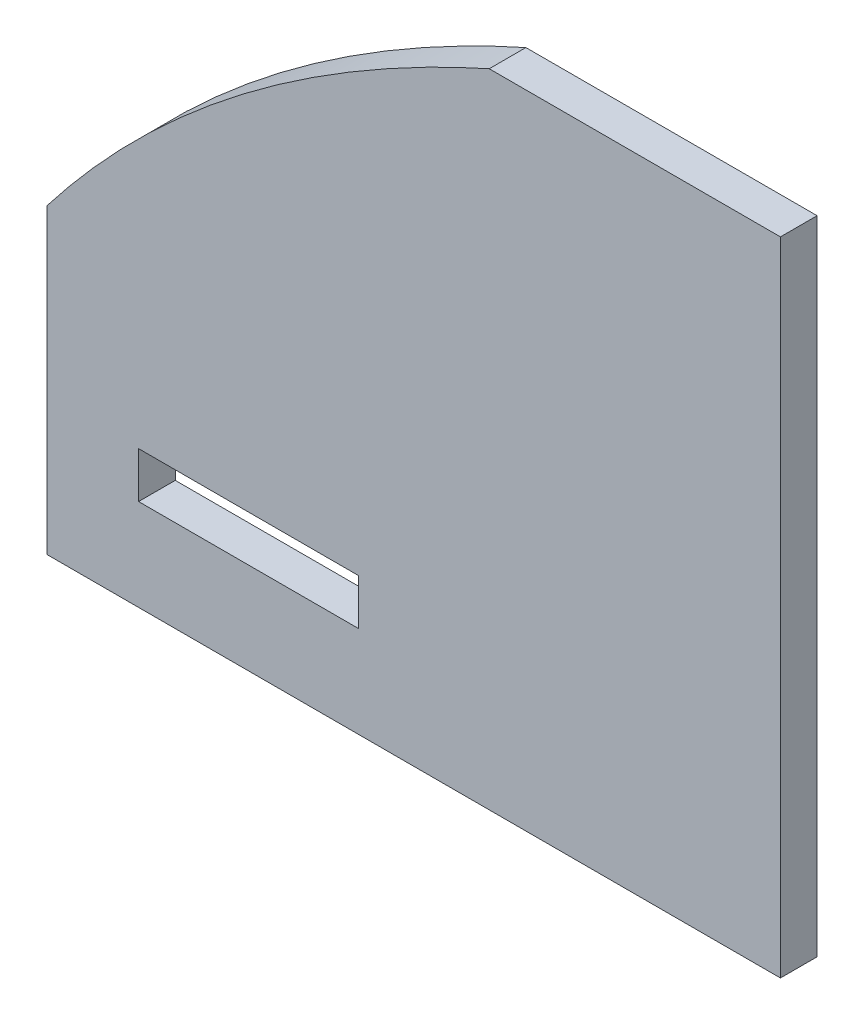
from build123d import *

# Parameters (mm, degrees)
ESQUISSE1_W             = 40
ESQUISSE1_H             = 35
ESQUISSE1_W_2           = 12
ESQUISSE1_H_2           = 2.5
BOSS_EXTRU_1_DEPTH      = 2
ENL_V_MAT_EXTRU_1_DEPTH = 10


with BuildPart() as part:
    # Esquisse1 → Boss.-Extru.1 (new body)
    with BuildSketch(Plane.XY):
        Rectangle(ESQUISSE1_W, ESQUISSE1_H)
        with Locations((-9, -11.25)):
            Rectangle(ESQUISSE1_W_2, ESQUISSE1_H_2, mode=Mode.SUBTRACT)
    extrude(amount=BOSS_EXTRU_1_DEPTH)

    # Esquisse2 → Enlèv. mat.-Extru.1 (cut)
    with BuildSketch(Plane.XY.offset(2)):
        with BuildLine():
            Line((-28.997409478, -17.623933779), (-30.265364491, 23.868234326))
            Line((-30.265364491, 23.868234326), (4.12, 17.5))
            add(Edge.make_bspline(
                [(4.12, 17.5), (-20.235504114, 6.589370836), (-28.997409478, -17.623933779)],
                knots=[0, 0, 0, 1, 1, 1], degree=2))
        make_face()
    extrude(amount=-ENL_V_MAT_EXTRU_1_DEPTH, mode=Mode.SUBTRACT)


solid = part.part
